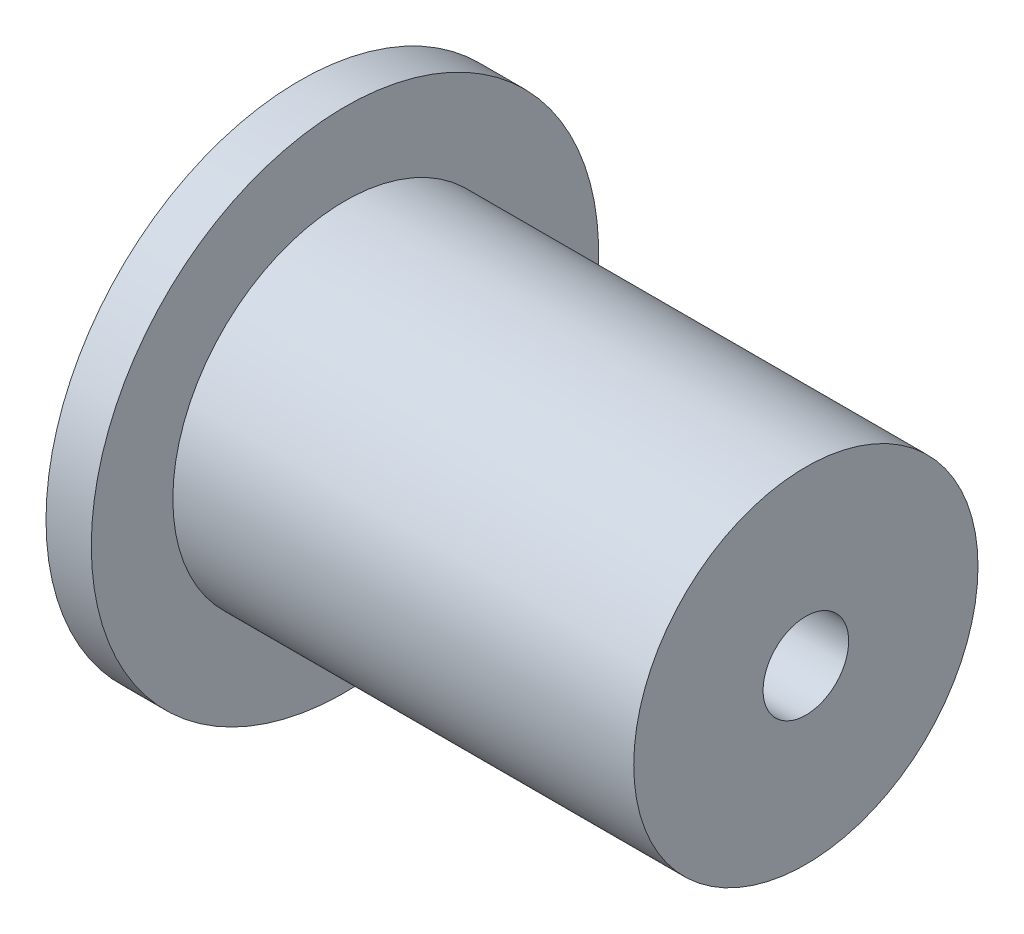
from build123d import *

# Parameters (mm, degrees)
SKETCH6_R          = 22.921214
SKETCH6_R_2        = 20.381214
CUT_EXTRUDE2_DEPTH = 1.3462


with BuildPart() as part:
    # Sketch1 → Revolve1 (revolve)
    with BuildSketch(Plane.XY):
        Polygon((0, 35.56), (6.35, 35.56), (6.35, 24.13), (70.9600054, 24.13), (70.9600054, 5.999988), (60.8000054, 5.999988), (60.8000054, 12.7), (48.1000054, 12.7), (48.1000054, 15.24), (22.7000054, 15.24), (22.7000054, 16.002), (12.7, 16.002), (12.7, 18.542), (0, 18.542), align=None)
    revolve(axis=Axis((0, 0, 0), (1, 0, 0)))

    # Sketch6 → Cut-Extrude2 (cut)
    with BuildSketch(Plane.ZY):
        Circle(SKETCH6_R)
        Circle(SKETCH6_R_2, mode=Mode.SUBTRACT)
    extrude(amount=-CUT_EXTRUDE2_DEPTH, mode=Mode.SUBTRACT)


solid = part.part
